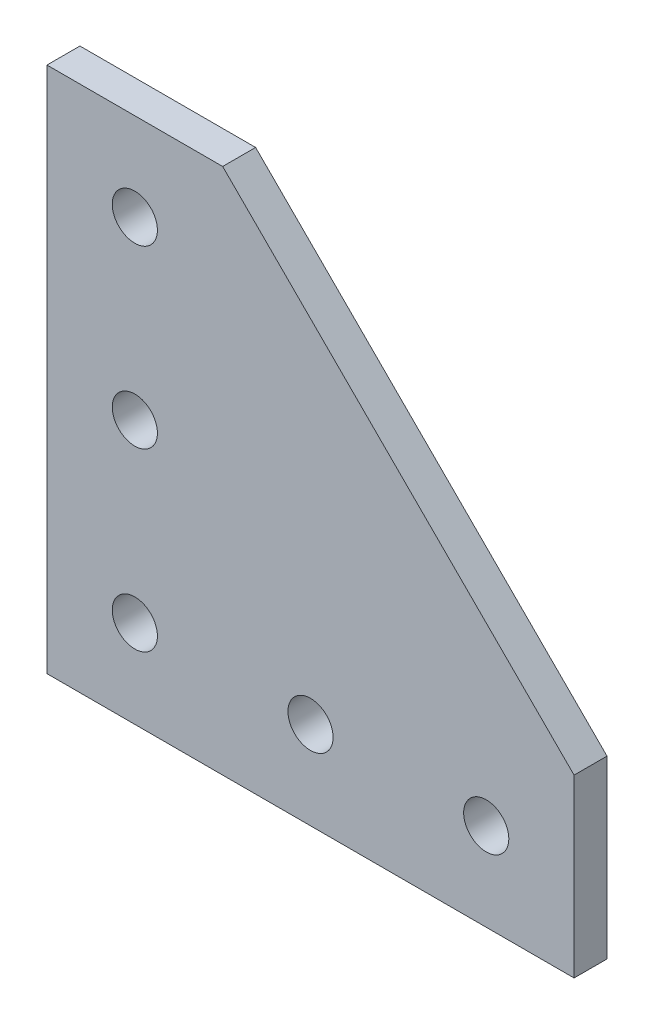
from build123d import *

# Parameters (mm, degrees)
SKETCH1_R           = 3.2639
BOSS_EXTRUDE1_DEPTH = 2.38125


with BuildPart() as part:
    # Sketch1 → Boss-Extrude1 (new body, symmetric)
    with BuildSketch(Plane.XY):
        Polygon((0, 0), (0, 76.2), (25.4, 76.2), (76.2, 25.4), (76.2, 0), align=None)
        with Locations((12.7, 12.7)):
            Circle(SKETCH1_R, mode=Mode.SUBTRACT)
        with Locations((38.1, 12.7)):
            Circle(SKETCH1_R, mode=Mode.SUBTRACT)
        with Locations((63.5, 12.7)):
            Circle(SKETCH1_R, mode=Mode.SUBTRACT)
        with Locations((12.7, 38.1)):
            Circle(SKETCH1_R, mode=Mode.SUBTRACT)
        with Locations((12.7, 63.5)):
            Circle(SKETCH1_R, mode=Mode.SUBTRACT)
    extrude(amount=BOSS_EXTRUDE1_DEPTH, both=True)


solid = part.part
